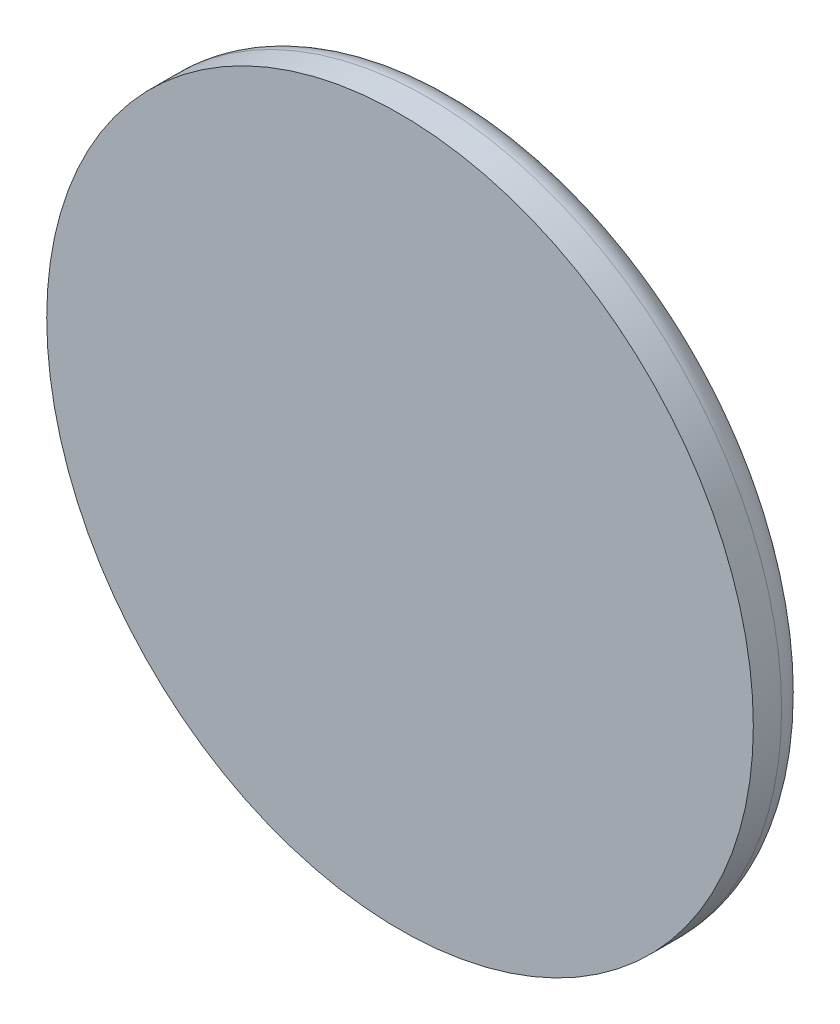
from build123d import *

# Parameters (mm, degrees)
BASE_SKETCH_R                                      = 62.5
BOSS_EXTRUDE1_DEPTH                                = 10
BOSS_EXTRUDE2_START                                = -10
BASE_SKETCH_3_R                                    = 10
BASE_SKETCH_3_R_2                                  = 5
BOSS_EXTRUDE2_DEPTH                                = 25
FILLET1_R                                          = 5
CHAMFER1_SIZE                                      = 2
CBORE_FOR_M2_5_HEX_HEAD_MACHINE_SCREW1_D           = 3.1
CBORE_FOR_M2_5_HEX_HEAD_MACHINE_SCREW1_CBORE_D     = 7.28
CBORE_FOR_M2_5_HEX_HEAD_MACHINE_SCREW1_CBORE_DEPTH = 2.1
CUT_EXTRUDE2_DEPTH                                 = 2.5


with BuildPart() as part:
    # Base_Sketch → Boss-Extrude1 (new body)
    with BuildSketch(Plane.XY):
        Circle(BASE_SKETCH_R)
    extrude(amount=-BOSS_EXTRUDE1_DEPTH)

    # Base_Sketch_3 → Boss-Extrude2 (add)
    with BuildSketch(Plane.XY.offset(BOSS_EXTRUDE2_START)):
        Circle(BASE_SKETCH_3_R)
        Circle(BASE_SKETCH_3_R_2, mode=Mode.SUBTRACT)
    extrude(amount=-BOSS_EXTRUDE2_DEPTH)

    # Fillet1
    fillet1_edges = [part.edges().sort_by_distance(p)[0] for p in [
        (-62.5, 0, -10),
        (-10, 0, -10),
    ]]
    fillet(fillet1_edges, radius=FILLET1_R)

    # Chamfer1
    chamfer1_edges = [part.edges().sort_by_distance(p)[0] for p in [
        (-10, 0, -35),
    ]]
    chamfer(chamfer1_edges, length=CHAMFER1_SIZE)

    # CBORE for M2.5 Hex Head Machine Screw1 (through all)
    with Locations(Plane(origin=(0, 10, -25), x_dir=(1, 0, 0), z_dir=(0, 1, 0))):
        with Locations((0, 0)):
            CounterBoreHole(CBORE_FOR_M2_5_HEX_HEAD_MACHINE_SCREW1_D / 2, CBORE_FOR_M2_5_HEX_HEAD_MACHINE_SCREW1_CBORE_D / 2, CBORE_FOR_M2_5_HEX_HEAD_MACHINE_SCREW1_CBORE_DEPTH)

    # Nut_Extrude → Cut-Extrude2 (cut)
    with BuildSketch(Plane(origin=(0, -10, -35), x_dir=(-1, 0, 0), z_dir=(0, -1, 0))):
        Polygon((2.875, -11.659882024), (2.875, -8.340117976), (0, -6.680235952), (-2.875, -8.340117976), (-2.875, -11.659882024), (0, -13.319764048), align=None)
    extrude(amount=-CUT_EXTRUDE2_DEPTH, mode=Mode.SUBTRACT)


solid = part.part
